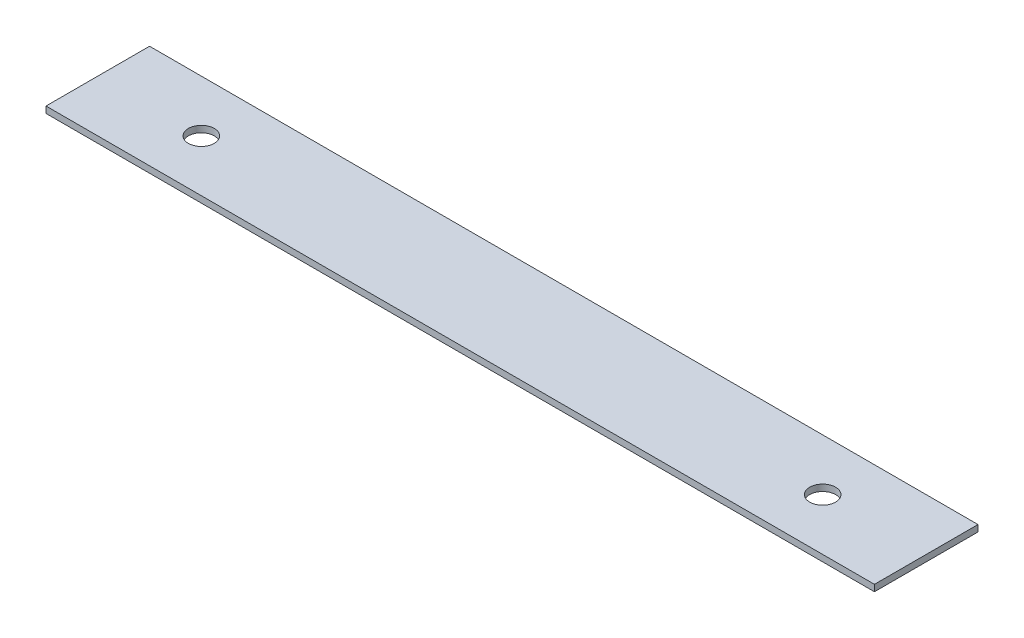
from build123d import *

# Parameters (mm, degrees)
SKETCH1_W           = 406.4
SKETCH1_H           = 50.8
SKETCH1_R           = 6.35
BOSS_EXTRUDE1_DEPTH = 3.175


with BuildPart() as part:
    # Sketch1 → Boss-Extrude1 (new body)
    with BuildSketch(Plane(origin=(0, 0, 0), x_dir=(1, 0, 0), z_dir=(0, 1, 0))):
        Rectangle(SKETCH1_W, SKETCH1_H)
        with Locations((-152.4, 0)):
            Circle(SKETCH1_R, mode=Mode.SUBTRACT)
        with Locations((152.4, 0)):
            Circle(SKETCH1_R, mode=Mode.SUBTRACT)
    extrude(amount=BOSS_EXTRUDE1_DEPTH)


solid = part.part
